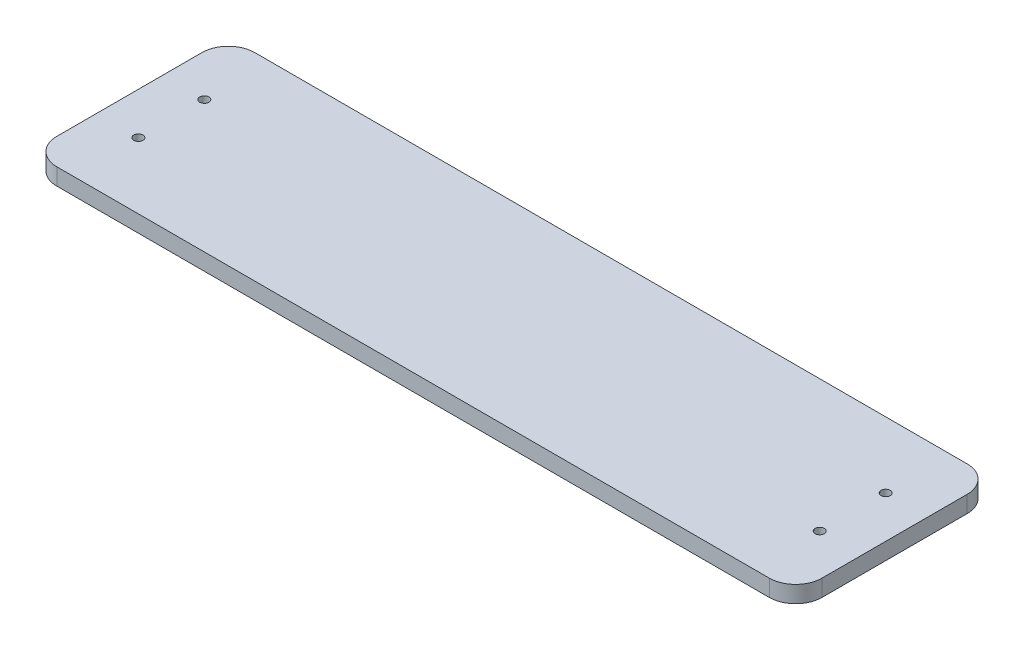
from build123d import *

# Parameters (mm, degrees)
SKETCH1_W           = 290
SKETCH1_H           = 75
BOSS_EXTRUDE1_DEPTH = 6.35
SKETCH3_R           = 1.75
CUT_EXTRUDE2_DEPTH  = 7.35
FILLET1_R           = 10
SKETCH4_R           = 1.75
CUT_EXTRUDE3_DEPTH  = 7.35
LPATTERN1_COUNT     = 2
LPATTERN1_PITCH     = 25


with BuildPart() as part:
    # Sketch1 → Boss-Extrude1 (new body)
    with BuildSketch(Plane(origin=(0, 0, 0), x_dir=(1, 0, 0), z_dir=(0, 1, 0))):
        Rectangle(SKETCH1_W, SKETCH1_H)
    extrude(amount=BOSS_EXTRUDE1_DEPTH)

    # Sketch3 → Cut-Extrude2 (cut, through all)
    with BuildSketch(Plane(origin=(0, 6.35, 0), x_dir=(1, 0, 0), z_dir=(0, 1, 0))):
        with Locations((129.12, 12.5)):
            Circle(SKETCH3_R)
    cut_extrude2 = extrude(amount=-CUT_EXTRUDE2_DEPTH, mode=Mode.SUBTRACT)

    # Fillet1
    fillet1_edges = [part.edges().sort_by_distance(p)[0] for p in [
        (145, 3.175, 37.5),
        (-145, 3.175, 37.5),
        (-145, 3.175, -37.5),
        (145, 3.175, -37.5),
    ]]
    fillet(fillet1_edges, radius=FILLET1_R)

    # Sketch4 → Cut-Extrude3 (cut, through all)
    with BuildSketch(Plane(origin=(0, 6.35, 0), x_dir=(1, 0, 0), z_dir=(0, 1, 0))):
        with Locations((-129.12, 12.5)):
            Circle(SKETCH4_R)
    cut_extrude3 = extrude(amount=-CUT_EXTRUDE3_DEPTH, mode=Mode.SUBTRACT)

    # LPattern1: Cut-Extrude2, Cut-Extrude3 ×2
    with Locations(*[(0, 0, i * LPATTERN1_PITCH) for i in range(1, LPATTERN1_COUNT)]):
        add(cut_extrude2, mode=Mode.SUBTRACT)
        add(cut_extrude3, mode=Mode.SUBTRACT)


solid = part.part
